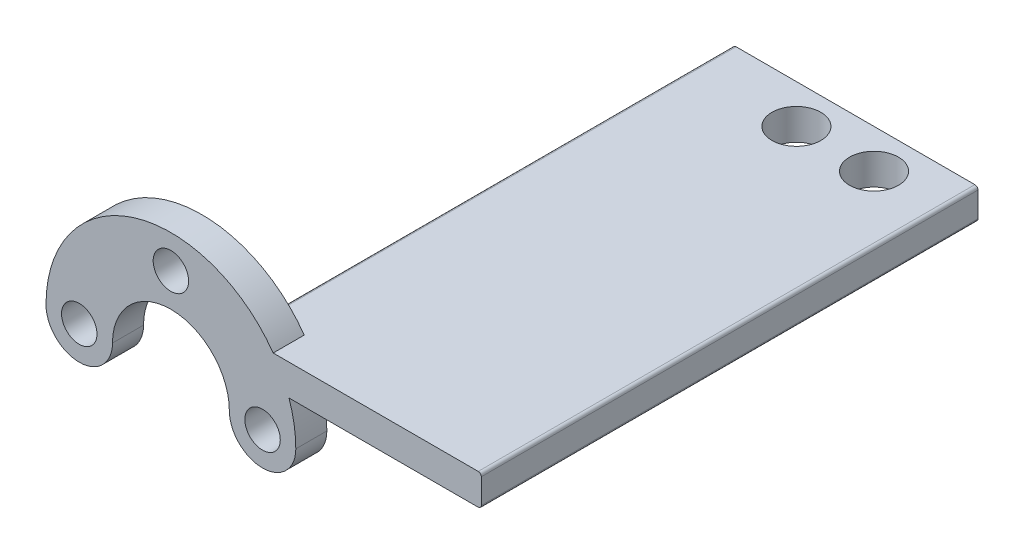
from build123d import *

# Parameters (mm, degrees)
SKETCH1_R           = 1.45
BOSS_EXTRUDE1_DEPTH = 2.54
BOSS_EXTRUDE2_DEPTH = 38.1
FILLET1_R           = 0.254
CUT_EXTRUDE1_DEPTH  = 19.05


with BuildPart() as part:
    # Sketch1 → Boss-Extrude1 (new body)
    with BuildSketch(Plane.XY):
        with BuildLine():
            ThreePointArc((10.22, 0), (10.07983069, 1.686835278), (9.663167661, 3.3274))
            Line((9.663167661, 3.3274), (25.4, 3.3274))
            Line((25.4, 3.3274), (25.4, 5.8674))
            Line((25.4, 5.8674), (8.367915944, 5.8674))
            ThreePointArc((8.367915944, 5.8674), (-3.076385784, 9.745986379), (-10.22, 1.2e-08))
            ThreePointArc((-10.22, 1.2e-08), (-7.500000006, -2.72), (-4.78, 0))
            ThreePointArc((-4.78, 0), (0, 4.78), (4.78, 0))
            ThreePointArc((4.78, 0), (7.5, -2.72), (10.22, 0))
        make_face()
        with Locations((7.5, 0)):
            Circle(SKETCH1_R, mode=Mode.SUBTRACT)
        with Locations((-7.5, 0)):
            Circle(SKETCH1_R, mode=Mode.SUBTRACT)
        with Locations((0, 7.5)):
            Circle(SKETCH1_R, mode=Mode.SUBTRACT)
    extrude(amount=BOSS_EXTRUDE1_DEPTH)

    # Sketch1_3 → Boss-Extrude2 (add)
    with BuildSketch(Plane.XY):
        with BuildLine():
            ThreePointArc((4.955402833, 5.8674), (6.072863387, 4.70135409), (6.921763449, 3.3274))
            Line((6.921763449, 3.3274), (25.4, 3.3274))
            Line((25.4, 3.3274), (25.4, 5.8674))
            Line((25.4, 5.8674), (4.955402833, 5.8674))
        make_face()
    extrude(amount=-BOSS_EXTRUDE2_DEPTH)

    # Fillet1
    fillet1_edges = [part.edges().sort_by_distance(p)[0] for p in [
        (25.4, 5.8674, -17.78),
        (25.4, 3.3274, -17.78),
        (4.955402833, 5.8674, -19.05),
        (6.921763449, 3.3274, -19.05),
    ]]
    fillet(fillet1_edges, radius=FILLET1_R)

    # Sketch5 → Cut-Extrude1 (cut)
    with BuildSketch(Plane(origin=(0, 5.8674, 0), x_dir=(1, 0, 0), z_dir=(0, 1, 0))):
        with BuildLine():
            Line((22.06625, 34.925), (20.066, 34.925))
            Line((20.066, 34.925), (18.06575, 34.925))
            ThreePointArc((18.06575, 34.925), (20.066, 32.92475), (22.06625, 34.925))
        make_face()
        with BuildLine():
            ThreePointArc((22.06625, 34.925), (21.480390339, 36.339390339), (20.066, 36.92525))
            Line((20.066, 36.92525), (20.066, 34.925))
            Line((20.066, 34.925), (22.06625, 34.925))
        make_face()
        with BuildLine():
            Line((20.066, 34.925), (20.066, 36.92525))
            ThreePointArc((20.066, 36.92525), (18.651609661, 36.339390339), (18.06575, 34.925))
            Line((18.06575, 34.925), (20.066, 34.925))
        make_face()
        with BuildLine():
            ThreePointArc((15.71625, 34.925), (13.716, 36.92525), (11.71575, 34.925))
            Line((11.71575, 34.925), (15.71625, 34.925))
        make_face()
        with BuildLine():
            Line((15.71625, 34.925), (11.71575, 34.925))
            ThreePointArc((11.71575, 34.925), (13.716, 32.92475), (15.71625, 34.925))
        make_face()
    extrude(amount=-CUT_EXTRUDE1_DEPTH, mode=Mode.SUBTRACT)


solid = part.part
